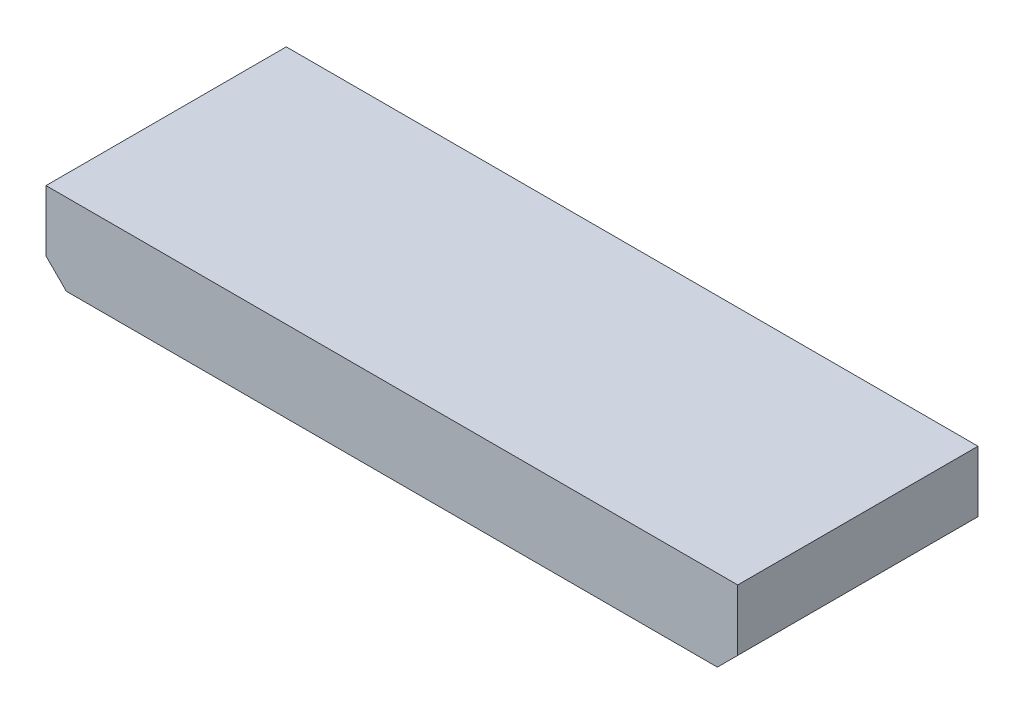
from build123d import *

# Parameters (mm, degrees)
COMPONENT_OUTLINE_DEPTH = 15
SKETCH2_R               = 0.25
EXTRUDE_1_DEPTH         = 2
SKETCH3_R               = 0.25
EXTRUDE_2_DEPTH         = 2
SKETCH4_R               = 0.25
EXTRUDE_3_DEPTH         = 2
SKETCH5_R               = 0.25
EXTRUDE_4_DEPTH         = 2
SKETCH6_R               = 0.25
EXTRUDE_5_DEPTH         = 2
SKETCH7_R               = 0.25
EXTRUDE_6_DEPTH         = 2
SKETCH8_R               = 0.25
EXTRUDE_7_DEPTH         = 2
SKETCH9_R               = 0.25
EXTRUDE_8_DEPTH         = 2
SKETCH10_R              = 0.25
EXTRUDE_9_DEPTH         = 2
SKETCH11_R              = 0.25
EXTRUDE_10_DEPTH        = 2
SKETCH12_R              = 0.25
EXTRUDE_11_DEPTH        = 2
SKETCH13_R              = 0.25
EXTRUDE_12_DEPTH        = 2
SKETCH14_R              = 0.25
EXTRUDE_13_DEPTH        = 2
SKETCH15_R              = 0.25
EXTRUDE_14_DEPTH        = 2


with BuildPart() as part:
    # Sketch1 → Component_Outline (new body)
    with BuildSketch(Plane.XY):
        Polygon((-5.08, 2.54), (-5.08, -1.27), (-3.81, -2.54), (36.83, -2.54), (38.1, -1.27), (38.1, 2.54), align=None)
    extrude(amount=COMPONENT_OUTLINE_DEPTH)


with BuildPart() as body_2:
    # Sketch2 → Extrude 1 (new body)
    with BuildSketch(Plane.XY):
        Circle(SKETCH2_R)
    extrude(amount=-EXTRUDE_1_DEPTH)


with BuildPart() as body_3:
    # Sketch3 → Extrude 2 (new body)
    with BuildSketch(Plane.XY):
        with Locations((2.54, 0)):
            Circle(SKETCH3_R)
    extrude(amount=-EXTRUDE_2_DEPTH)


with BuildPart() as body_4:
    # Sketch4 → Extrude 3 (new body)
    with BuildSketch(Plane.XY):
        with Locations((5.08, 0)):
            Circle(SKETCH4_R)
    extrude(amount=-EXTRUDE_3_DEPTH)


with BuildPart() as body_5:
    # Sketch5 → Extrude 4 (new body)
    with BuildSketch(Plane.XY):
        with Locations((7.62, 0)):
            Circle(SKETCH5_R)
    extrude(amount=-EXTRUDE_4_DEPTH)


with BuildPart() as body_6:
    # Sketch6 → Extrude 5 (new body)
    with BuildSketch(Plane.XY):
        with Locations((10.16, 0)):
            Circle(SKETCH6_R)
    extrude(amount=-EXTRUDE_5_DEPTH)


with BuildPart() as body_7:
    # Sketch7 → Extrude 6 (new body)
    with BuildSketch(Plane.XY):
        with Locations((12.7, 0)):
            Circle(SKETCH7_R)
    extrude(amount=-EXTRUDE_6_DEPTH)


with BuildPart() as body_8:
    # Sketch8 → Extrude 7 (new body)
    with BuildSketch(Plane.XY):
        with Locations((15.24, 0)):
            Circle(SKETCH8_R)
    extrude(amount=-EXTRUDE_7_DEPTH)


with BuildPart() as body_9:
    # Sketch9 → Extrude 8 (new body)
    with BuildSketch(Plane.XY):
        with Locations((17.78, 0)):
            Circle(SKETCH9_R)
    extrude(amount=-EXTRUDE_8_DEPTH)


with BuildPart() as body_10:
    # Sketch10 → Extrude 9 (new body)
    with BuildSketch(Plane.XY):
        with Locations((20.32, 0)):
            Circle(SKETCH10_R)
    extrude(amount=-EXTRUDE_9_DEPTH)


with BuildPart() as body_11:
    # Sketch11 → Extrude 10 (new body)
    with BuildSketch(Plane.XY):
        with Locations((22.86, 0)):
            Circle(SKETCH11_R)
    extrude(amount=-EXTRUDE_10_DEPTH)


with BuildPart() as body_12:
    # Sketch12 → Extrude 11 (new body)
    with BuildSketch(Plane.XY):
        with Locations((25.4, 0)):
            Circle(SKETCH12_R)
    extrude(amount=-EXTRUDE_11_DEPTH)


with BuildPart() as body_13:
    # Sketch13 → Extrude 12 (new body)
    with BuildSketch(Plane.XY):
        with Locations((27.94, 0)):
            Circle(SKETCH13_R)
    extrude(amount=-EXTRUDE_12_DEPTH)


with BuildPart() as body_14:
    # Sketch14 → Extrude 13 (new body)
    with BuildSketch(Plane.XY):
        with Locations((30.48, 0)):
            Circle(SKETCH14_R)
    extrude(amount=-EXTRUDE_13_DEPTH)


with BuildPart() as body_15:
    # Sketch15 → Extrude 14 (new body)
    with BuildSketch(Plane.XY):
        with Locations((33.02, 0)):
            Circle(SKETCH15_R)
    extrude(amount=-EXTRUDE_14_DEPTH)


solid = Compound([part.part, body_2.part, body_3.part, body_4.part, body_5.part, body_6.part, body_7.part, body_8.part, body_9.part, body_10.part, body_11.part, body_12.part, body_13.part, body_14.part, body_15.part])
